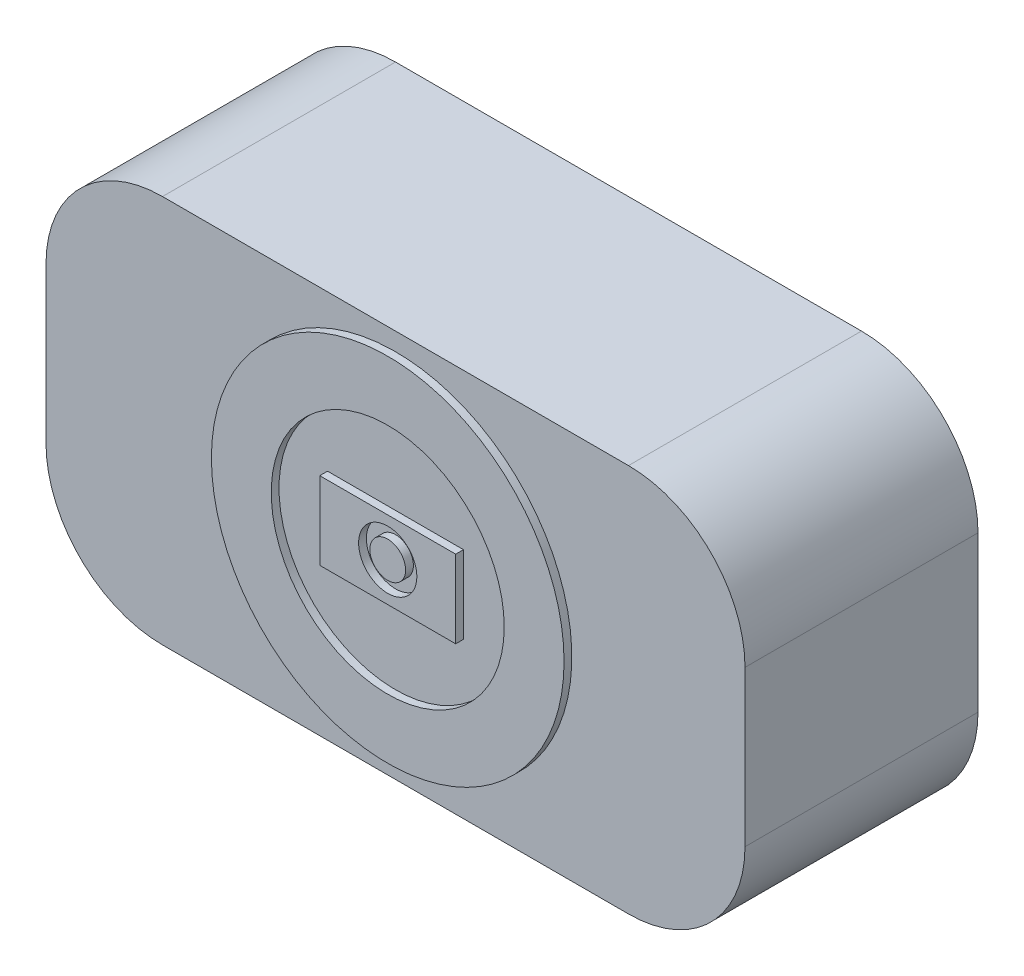
from build123d import *

# Parameters (mm, degrees)
SKETCH1_W           = 90
SKETCH1_H           = 50
BOSS_EXTRUDE1_DEPTH = 30
FILLET1_R           = 15
SKETCH2_R           = 22.703438641
BOSS_EXTRUDE2_DEPTH = 1
SKETCH3_R           = 15
CUT_EXTRUDE1_DEPTH  = 1
SKETCH4_W           = 17.5
SKETCH4_H           = 10
BOSS_EXTRUDE3_DEPTH = 1
SKETCH5_R           = 3.75
CUT_EXTRUDE2_DEPTH  = 1
SKETCH6_R           = 2.30333071
BOSS_EXTRUDE4_DEPTH = 1


with BuildPart() as part:
    # Sketch1 → Boss-Extrude1 (new body)
    with BuildSketch(Plane.XY):
        with Locations((45, 25)):
            Rectangle(SKETCH1_W, SKETCH1_H)
    extrude(amount=-BOSS_EXTRUDE1_DEPTH)

    # Fillet1
    fillet1_edges = [part.edges().sort_by_distance(p)[0] for p in [
        (0, 50, -15),
        (90, 50, -15),
        (90, 0, -15),
        (0, 0, -15),
    ]]
    fillet(fillet1_edges, radius=FILLET1_R)

    # Sketch2 → Boss-Extrude2 (add)
    with BuildSketch(Plane.XY):
        with Locations((45, 25)):
            Circle(SKETCH2_R)
    extrude(amount=BOSS_EXTRUDE2_DEPTH)

    # Sketch3 → Cut-Extrude1 (cut)
    with BuildSketch(Plane.XY.offset(1)):
        with Locations((45, 25)):
            Circle(SKETCH3_R)
    extrude(amount=-CUT_EXTRUDE1_DEPTH, mode=Mode.SUBTRACT)

    # Sketch4 → Boss-Extrude3 (add)
    with BuildSketch(Plane.XY):
        with Locations((45, 25)):
            Rectangle(SKETCH4_W, SKETCH4_H)
    extrude(amount=BOSS_EXTRUDE3_DEPTH)

    # Sketch5 → Cut-Extrude2 (cut)
    with BuildSketch(Plane.XY.offset(1)):
        with Locations((45, 25)):
            Circle(SKETCH5_R)
    extrude(amount=-CUT_EXTRUDE2_DEPTH, mode=Mode.SUBTRACT)

    # Sketch6 → Boss-Extrude4 (add)
    with BuildSketch(Plane.XY):
        with Locations((45, 25)):
            Circle(SKETCH6_R)
    extrude(amount=BOSS_EXTRUDE4_DEPTH)


solid = part.part
